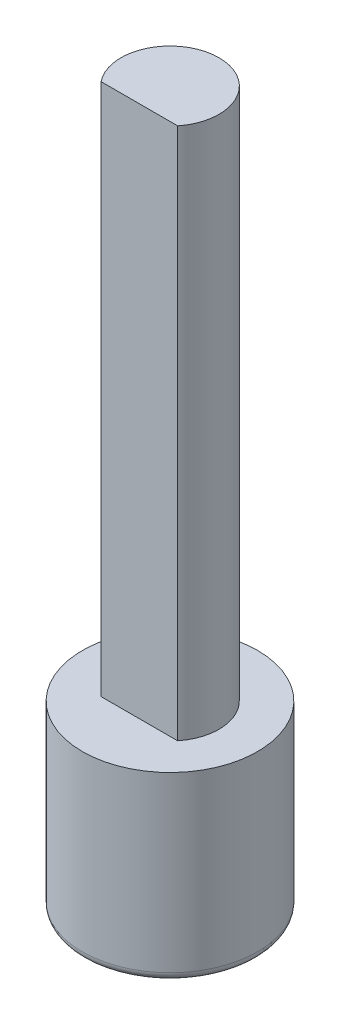
from build123d import *

# Parameters (mm, degrees)
FILLET1_R          = 0.25
CUT_EXTRUDE1_DEPTH = 15.2


with BuildPart() as part:
    # Sketch2 → Revolve1 (revolve)
    with BuildSketch(Plane(origin=(0, 0, 0), x_dir=(0, 0, -1), z_dir=(1, 0, 0))):
        Polygon((0, 0), (2.5, 0), (2.5, 5.2), (1.4, 5.2), (1.4, 20.4), (0, 20.4), align=None)
    revolve(axis=Axis((0, 20.4, 0), (0, -1, 0)))

    # Fillet1
    fillet1_edges = [part.edges().sort_by_distance(p)[0] for p in [
        (0, 0, 2.5),
    ]]
    fillet(fillet1_edges, radius=FILLET1_R)

    # Sketch3 → Cut-Extrude1 (cut)
    with BuildSketch(Plane(origin=(0, 20.4, 0), x_dir=(1, 0, 0), z_dir=(0, 1, 0))):
        with BuildLine():
            Line((1.09287465, -0.875), (-1.09287465, -0.875))
            ThreePointArc((-1.09287465, -0.875), (0, -1.4), (1.09287465, -0.875))
        make_face()
    extrude(amount=-CUT_EXTRUDE1_DEPTH, mode=Mode.SUBTRACT)


solid = part.part
